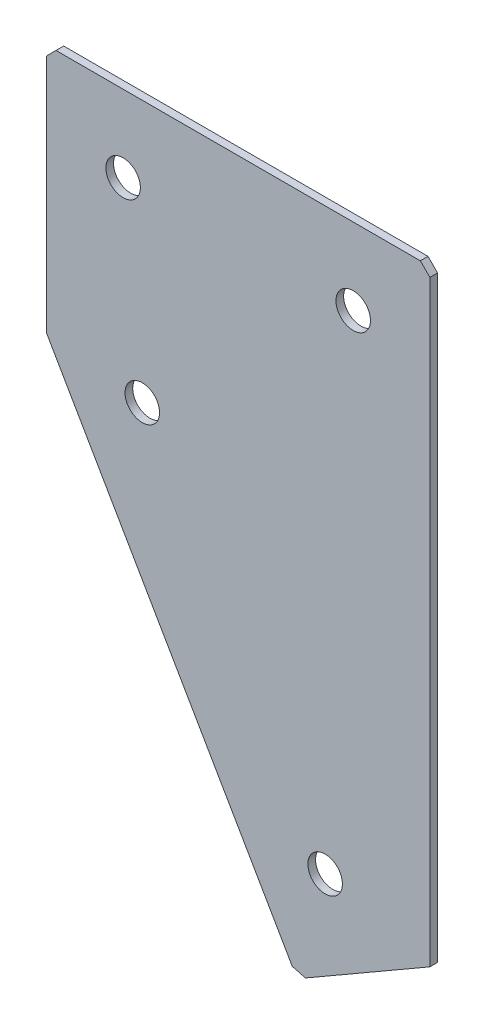
from build123d import *

# Parameters (mm, degrees)
EXTRUDE_1_DEPTH   = 2
HOLE_WIZARD_M81_D = 9
CHAMFER_1_SIZE    = 2.5


with BuildPart() as part:
    # Эскиз3 → Бобышка-Вытянуть1 (new body)
    with BuildSketch(Plane(origin=(0, 0, 0), x_dir=(1, 0, 0), z_dir=(0, 0, -1))):
        Polygon((0, 0), (100, 0), (100, 158.205080757), (65.358983849, 178.205080757), (0, 65), align=None)
    extrude(amount=EXTRUDE_1_DEPTH)

    # Отверстие с зазором M81 (through all)
    with Locations(Plane(origin=(0, 0, -2), x_dir=(1, 0, 0), z_dir=(0, 0, -1))):
        with Locations((20, 20), (80, 20), (25, 68.301270189), (72.679491924, 150.884572681)):
            Hole(HOLE_WIZARD_M81_D / 2)

    # Фаска1
    chamfer_1_edges = [part.edges().sort_by_distance(p)[0] for p in [
        (65.358983849, -178.205080757, -1),
        (100, 0, -1),
        (0, 0, -1),
    ]]
    chamfer(chamfer_1_edges, length=CHAMFER_1_SIZE)


solid = part.part
